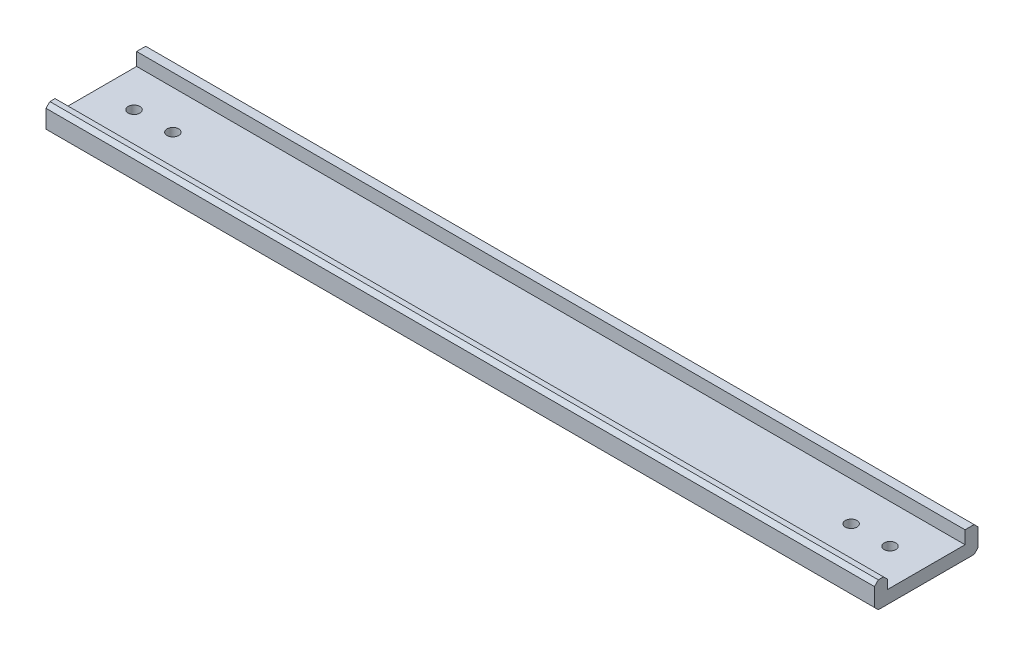
from build123d import *

# Parameters (mm, degrees)
SALIENTE_EXTRUIR1_DEPTH = 160
CHAFL_N1_SIZE           = 1.5
CROQUIS2_R              = 2.25
CORTAR_EXTRUIR1_DEPTH   = 320


with BuildPart() as part:
    # Croquis1 → Saliente-Extruir1 (new body, symmetric)
    with BuildSketch(Plane(origin=(0, 0, 0), x_dir=(0, 0, -1), z_dir=(1, 0, 0))):
        Polygon((-15, 0), (15, 0), (15, 5), (20, 5), (20, -5), (-20, -5), (-20, 5), (-15, 5), align=None)
    extrude(amount=SALIENTE_EXTRUIR1_DEPTH, both=True)

    # Chaflán1
    chafl_n1_edges = [part.edges().sort_by_distance(p)[0] for p in [
        (0, 5, -20),
        (0, -5, -20),
        (0, -5, 20),
        (0, 5, 20),
        (0, 5, 15),
    ]]
    chamfer(chafl_n1_edges, length=CHAFL_N1_SIZE)

    # Croquis2 → Cortar-Extruir1 (cut)
    with BuildSketch(Plane(origin=(0, 0, 0), x_dir=(1, 0, 0), z_dir=(0, 1, 0))):
        with Locations((-146, 0)):
            Circle(CROQUIS2_R)
        with Locations((-131, 0)):
            Circle(CROQUIS2_R)
        with Locations((131, 0)):
            Circle(CROQUIS2_R)
        with Locations((146, 0)):
            Circle(CROQUIS2_R)
    extrude(amount=-CORTAR_EXTRUIR1_DEPTH, mode=Mode.SUBTRACT)


solid = part.part
